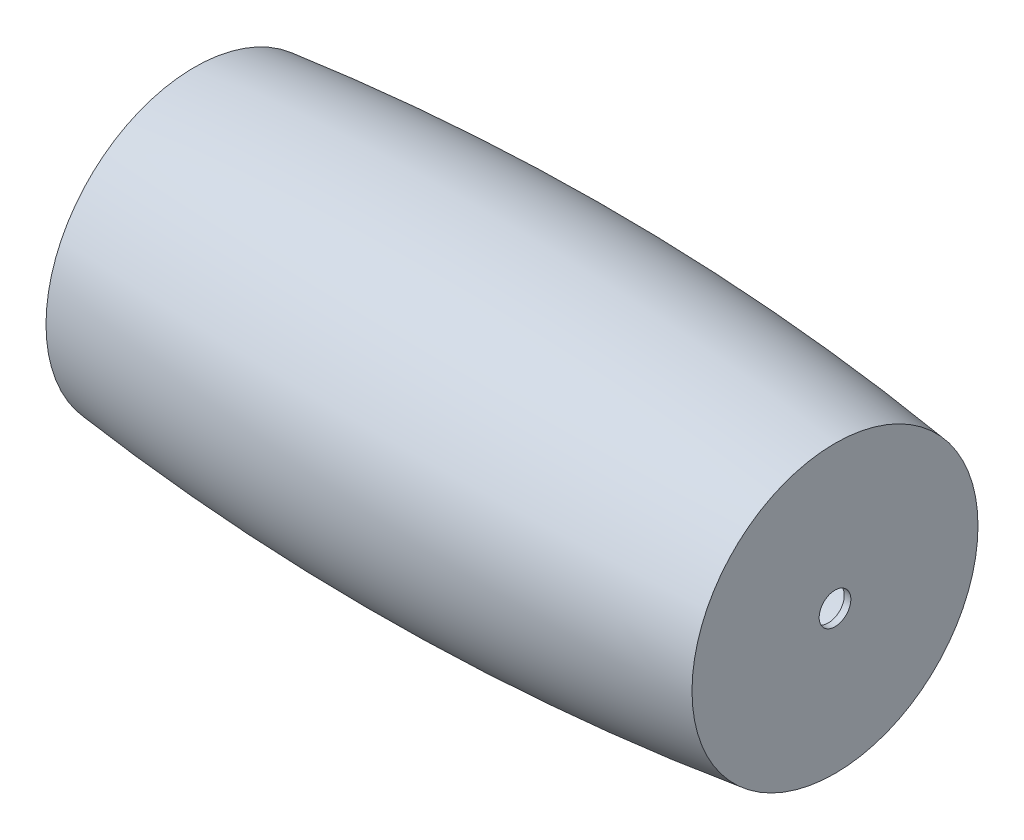
from build123d import *

# Parameters (mm, degrees)
SKETCH_2_R          = 24
CUT_EXTRUDE_1_DEPTH = 971.0000001


with BuildPart() as part:
    # Эскиз1 → Повернуть1 (revolve)
    with BuildSketch(Plane.XY):
        with BuildLine():
            Line((0, 21.920416175), (0, 31.9824899))
            ThreePointArc((0, 31.9824899), (485.252139471, 56.829537687), (970, 23.565046761))
            Line((970, 23.565046761), (970, -193.0175101))
            Line((970, -193.0175101), (960, -193.0175101))
            Line((960, -193.0175101), (960, 14.763108215))
            ThreePointArc((960, 14.763108215), (480.212692106, 46.869865662), (0, 21.920416175))
        make_face()
    revolve(axis=Axis((960, -193.0175101, 0), (1, 0, 0)))

    # Эскиз2 → Вырез-Вытянуть1 (cut, through all)
    with BuildSketch(Plane.ZY):
        with Locations((0, -193.0175101)):
            Circle(SKETCH_2_R)
    extrude(amount=-CUT_EXTRUDE_1_DEPTH, mode=Mode.SUBTRACT)


solid = part.part
